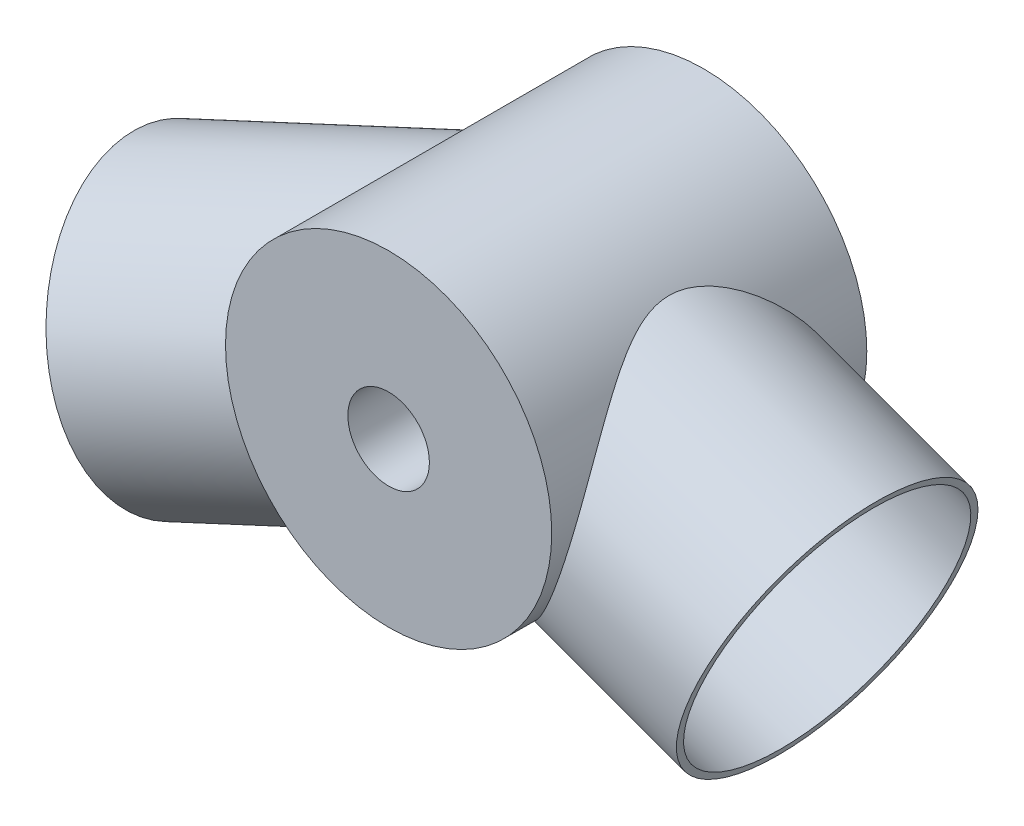
from build123d import *

# Parameters (mm, degrees)
SKETCH1_R           = 12
BOSS_EXTRUDE1_DEPTH = 11.59
EXTRUDE_THIN2_START = -4.1
SKETCH8_R           = 10.5
SKETCH8_R_2         = 10
EXTRUDE_THIN2_DEPTH = 22
SKETCH3_R           = 10.5
SKETCH3_R_2         = 10
EXTRUDE_THIN1_DEPTH = 22
SKETCH4_R           = 7.5
CUT_EXTRUDE1_DEPTH  = 10
SKETCH5_R           = 3
CUT_EXTRUDE2_DEPTH  = 24.1800001


with BuildPart() as part:
    # Sketch1 → Boss-Extrude1 (new body, symmetric)
    with BuildSketch(Plane.XY):
        Circle(SKETCH1_R)
    extrude(amount=BOSS_EXTRUDE1_DEPTH, both=True)

    # Sketch8 → Extrude-Thin2 (add)
    with BuildSketch(Plane(origin=(0, 0, 0), x_dir=(-0.342020143, 0.939692621, 0), z_dir=(0.925416578, 0.336824089, -0.173648178)).offset(EXTRUDE_THIN2_START)):
        with Locations((0, -1.5)):
            Circle(SKETCH8_R)
        with Locations((0, -1.5)):
            Circle(SKETCH8_R_2, mode=Mode.SUBTRACT)
    extrude(amount=-EXTRUDE_THIN2_DEPTH)

    # Sketch3 → Extrude-Thin1 (add)
    with BuildSketch(Plane(origin=(0, 0, 0), x_dir=(0, 0, -1), z_dir=(0.939692621, -0.342020143, 0))):
        Circle(SKETCH3_R)
        Circle(SKETCH3_R_2, mode=Mode.SUBTRACT)
    extrude(amount=EXTRUDE_THIN1_DEPTH)

    # Sketch4 → Cut-Extrude1 (cut)
    with BuildSketch(Plane(origin=(0, 0, -11.59), x_dir=(-1, 0, 0), z_dir=(0, 0, -1))):
        Circle(SKETCH4_R)
    extrude(amount=-CUT_EXTRUDE1_DEPTH, mode=Mode.SUBTRACT)

    # Sketch5 → Cut-Extrude2 (cut, through all)
    with BuildSketch(Plane.XY.offset(11.59)):
        Circle(SKETCH5_R)
    extrude(amount=-CUT_EXTRUDE2_DEPTH, mode=Mode.SUBTRACT)


solid = part.part
